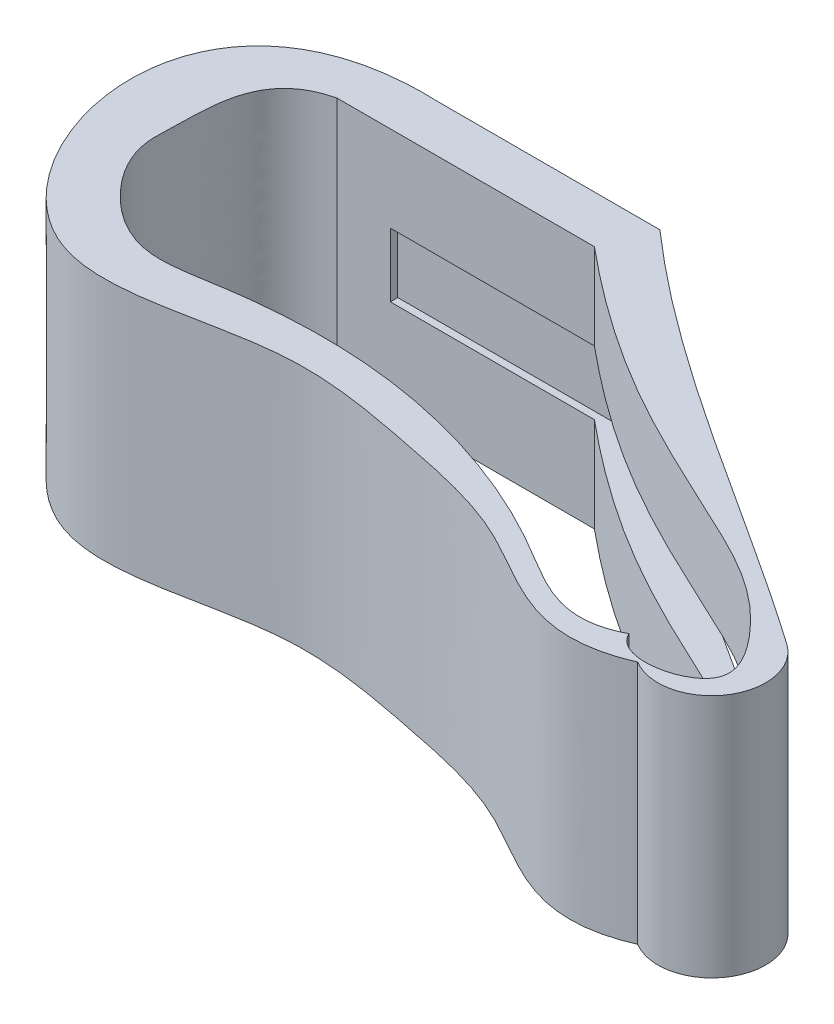
from build123d import *

# Parameters (mm, degrees)
BOSS_EXTRUDE1_DEPTH = 55
SKETCH3_R           = 5
CUT_EXTRUDE1_DEPTH  = 7
CUT_EXTRUDE2_DEPTH  = 69
SKETCH5_W           = 54.072178916
SKETCH5_H           = 14.37361718
CUT_EXTRUDE3_DEPTH  = 144


with BuildPart() as part:
    # Sketch1 → Boss-Extrude1 (new body)
    with BuildSketch(Plane(origin=(0, 0, 0), x_dir=(1, 0, 0), z_dir=(0, 1, 0))):
        with BuildLine():
            Line((0, 0), (50, 0))
            add(Edge.make_bspline(
                [(50, 0), (79.02452504, -25.513493785), (113.333333333, -44.298245614), (145, -66.447368421)],
                knots=[0, 0, 0, 0, 1, 1, 1, 1], degree=3))
            ThreePointArc((145, -66.447368421), (148.198132014, -83.010879333), (131.743129046, -86.727170416))
            add(Edge.make_bspline(
                [(131.743129046, -86.727170416), (113.423676908, -94.627943088), (95.656849667, -76.755295672), (61.716581188, -69.880042533), (27.533977158, -63.350234093), (-34.902240082, -90.069698203), (-56.897241406, 2.246913206), (0, 0)],
                knots=[0, 0, 0, 0, 0.17779936, 0.292227638, 0.418536619, 0.610683724, 1, 1, 1, 1], degree=3))
        make_face()
    extrude(amount=BOSS_EXTRUDE1_DEPTH)

    # Sketch3 → Cut-Extrude1 (cut)
    with BuildSketch(Plane(origin=(0, 0, 0), x_dir=(-1, 0, 0), z_dir=(0, 0, -1))):
        with Locations((-25, 27.5)):
            Circle(SKETCH3_R)
    extrude(amount=-CUT_EXTRUDE1_DEPTH, mode=Mode.SUBTRACT)

    # Sketch4 → Cut-Extrude2 (cut)
    with BuildSketch(Plane.XZ):
        with BuildLine():
            Line((45.919818566, 10.653864558), (-11.990720487, 10.653864558))
            add(Edge.make_bspline(
                [(-11.990720487, 10.653864558), (-25.59603624, 13.82850716), (-24.369383918, 27.601677579), (-25.204175969, 43.578563496), (-18.771719351, 54.405758795), (-4.938421362, 63.685295765), (16.865274127, 59.084953931), (51.589224441, 57.30747583), (90.507664472, 70.071776882), (114.302121814, 87.833368244), (125.220110654, 82.180802965)],
                knots=[0, 0, 0, 0, 0.142783016, 0.15926452, 0.237664021, 0.31903631, 0.395894995, 0.562922971, 0.851387633, 1, 1, 1, 1], degree=3))
            add(Edge.make_bspline(
                [(125.220110654, 82.180802965), (128.040973738, 88.549534927), (149.853952229, 84.370202192), (134.936663637, 61.411286394), (98.341658807, 43.711844545), (72.438232015, 32.653695763), (45.919818566, 10.653864558)],
                knots=[0, 0, 0, 0, 0.144149385, 0.229521181, 0.450932314, 1, 1, 1, 1], degree=3))
        make_face()
    extrude(amount=-CUT_EXTRUDE2_DEPTH, mode=Mode.SUBTRACT)

    # Sketch5 → Cut-Extrude3 (cut)
    with BuildSketch(Plane(origin=(0, 0, 0), x_dir=(0, 0, -1), z_dir=(1, 0, 0))):
        with Locations((-36.025766145, 28.477797087)):
            Rectangle(SKETCH5_W, SKETCH5_H)
    extrude(amount=CUT_EXTRUDE3_DEPTH, mode=Mode.SUBTRACT)


solid = part.part
